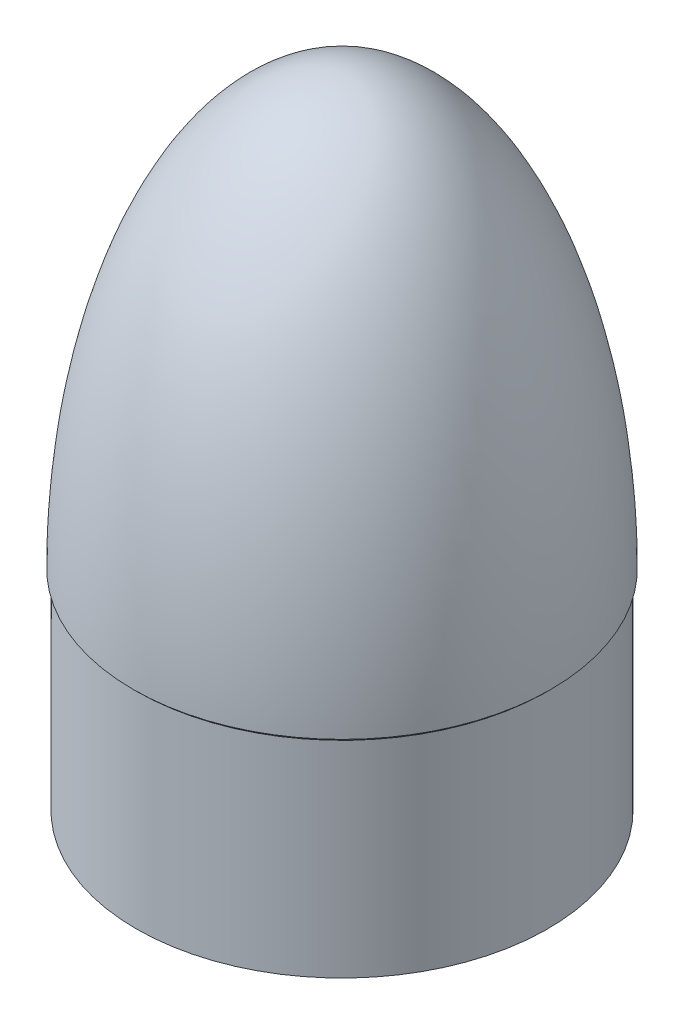
from build123d import *


with BuildPart() as part:
    # Sketch1 → Revolve1 (revolve)
    with BuildSketch(Plane.XY):
        with BuildLine():
            Line((0, 165.1), (0, 162.1028))
            add(Edge.make_bspline(
                [(79.315278355, 1.342862767), (78.663627327, 162.1028), (0, 162.1028)],
                knots=[4.720673095, 4.720673095, 4.720673095, 6.283185307, 6.283185307, 6.283185307], degree=2, weights=[1, 0.710029584, 1]))
            Line((79.315278355, 1.342862767), (77.575, -0.397415588))
            Line((77.575, -0.397415588), (77.575, -80.518))
            Line((77.575, -80.518), (79.375, -80.518))
            Line((79.375, -80.518), (79.375, -1.143))
            Line((79.375, -1.143), (80.518, 0))
            add(Edge.make_bspline(
                [(80.518, 0), (80.518, 165.1), (0, 165.1)],
                knots=[1.570796327, 1.570796327, 1.570796327, 3.141592654, 3.141592654, 3.141592654], degree=2, weights=[1, 0.707106781, 1]))
        make_face()
    revolve(axis=Axis((0, 165.1, 0), (0, -1, 0)))


solid = part.part
